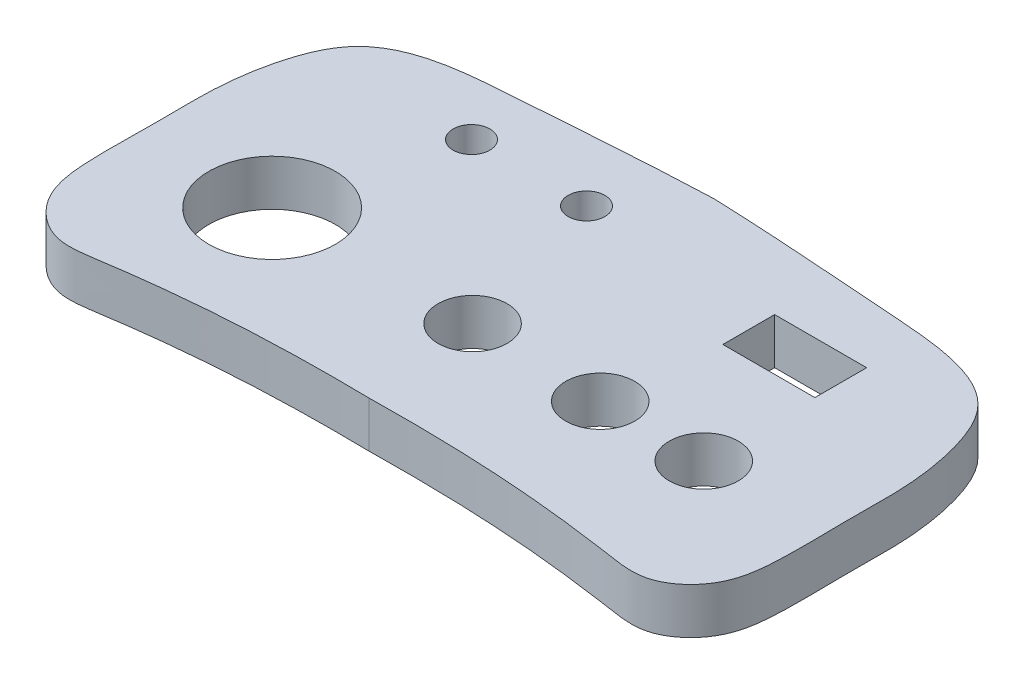
from build123d import *

# Parameters (mm, degrees)
Y_KSEKLIK_EKSTR_ZYON1_DEPTH = 4
IZIM2_R                     = 5.5
IZIM2_R_2                   = 3
IZIM2_R_3                   = 1.6
IZIM2_W                     = 8
IZIM2_H                     = 4.5
KES_EKSTR_ZYON1_DEPTH       = 10


with BuildPart() as part:
    # Çizim1 → Yükseklik-Ekstrüzyon1 (new body)
    with BuildSketch(Plane(origin=(0, 0, 0), x_dir=(1, 0, 0), z_dir=(0, 1, 0))):
        with BuildLine():
            add(Edge.make_bspline(
                [(0, 17.928841308), (-5.820212095, 17.709536244), (-13.903357487, 17.042587637), (-26.87571665, 16.196014495), (-29.550286899, 8.929250371), (-30.090469717, 4.336098712), (-29.940693307, -0.887353996), (-30.154927851, -5.701691423), (-29.637182829, -10.928766593), (-26.031174583, -14.081750554), (-15.720131404, -12.349312728), (-7.807226576, -11.938879102), (0, -12.071158692)],
                knots=[0, 0, 0, 0, 0.198459501, 0.336012796, 0.394476639, 0.459729731, 0.505376957, 0.582750838, 0.635932872, 0.690008906, 0.731880659, 1, 1, 1, 1], degree=3))
            add(Edge.make_bspline(
                [(0, 17.928841308), (5.820212095, 17.709536244), (13.903357487, 17.042587637), (26.87571665, 16.196014495), (29.550286899, 8.929250371), (30.090469717, 4.336098712), (29.940693307, -0.887353996), (30.154927851, -5.701691423), (29.637182829, -10.928766593), (26.031174583, -14.081750554), (15.720131404, -12.349312728), (7.807226576, -11.938879102), (0, -12.071158692)],
                knots=[0, 0, 0, 0, 0.198459501, 0.336012796, 0.394476639, 0.459729731, 0.505376957, 0.582750838, 0.635932872, 0.690008906, 0.731880659, 1, 1, 1, 1], degree=3))
        make_face()
    extrude(amount=Y_KSEKLIK_EKSTR_ZYON1_DEPTH)

    # Çizim2 → Kes-Ekstrüzyon1 (cut)
    with BuildSketch(Plane(origin=(0, 4, 0), x_dir=(1, 0, 0), z_dir=(0, 1, 0))):
        with Locations((-18.527748167, -1.962499381)):
            Circle(IZIM2_R)
        with Locations((-1.102266972, -1.962499381)):
            Circle(IZIM2_R_2)
        with Locations((10.293462547, -2.261963976)):
            Circle(IZIM2_R_2)
        with Locations((19.293462547, -2.261963976)):
            Circle(IZIM2_R_2)
        with Locations((-15.002033729, 11.84202604)):
            Circle(IZIM2_R_3)
        with Locations((-5.002033729, 11.84202604)):
            Circle(IZIM2_R_3)
        with Locations((15.3495328, 9.59202604)):
            Rectangle(IZIM2_W, IZIM2_H)
    extrude(amount=-KES_EKSTR_ZYON1_DEPTH, mode=Mode.SUBTRACT)


solid = part.part
